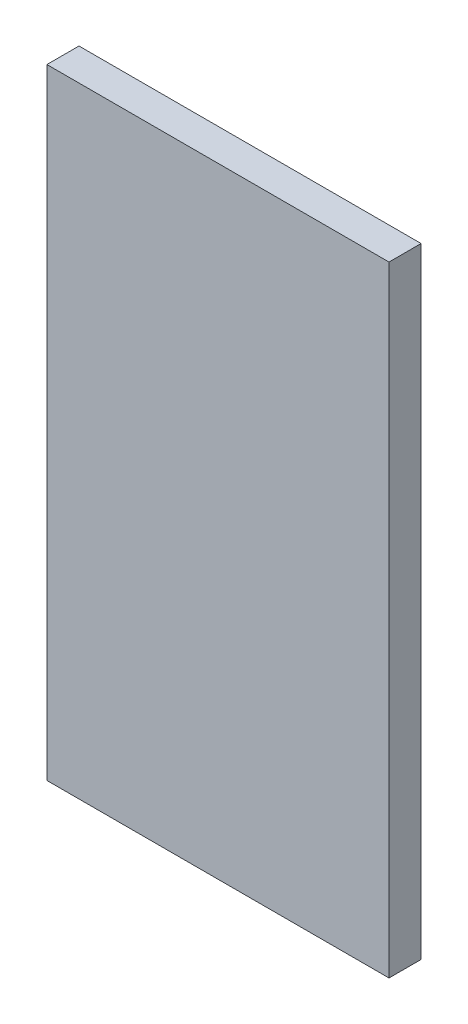
from build123d import *

# Parameters (mm, degrees)
ESQUISSE1_W        = 32
ESQUISSE1_H        = 58
BOSS_EXTRU_1_DEPTH = 3


with BuildPart() as part:
    # Esquisse1 → Boss.-Extru.1 (new body)
    with BuildSketch(Plane.XY):
        with Locations((16, -29)):
            Rectangle(ESQUISSE1_W, ESQUISSE1_H)
    extrude(amount=BOSS_EXTRU_1_DEPTH)


solid = part.part
